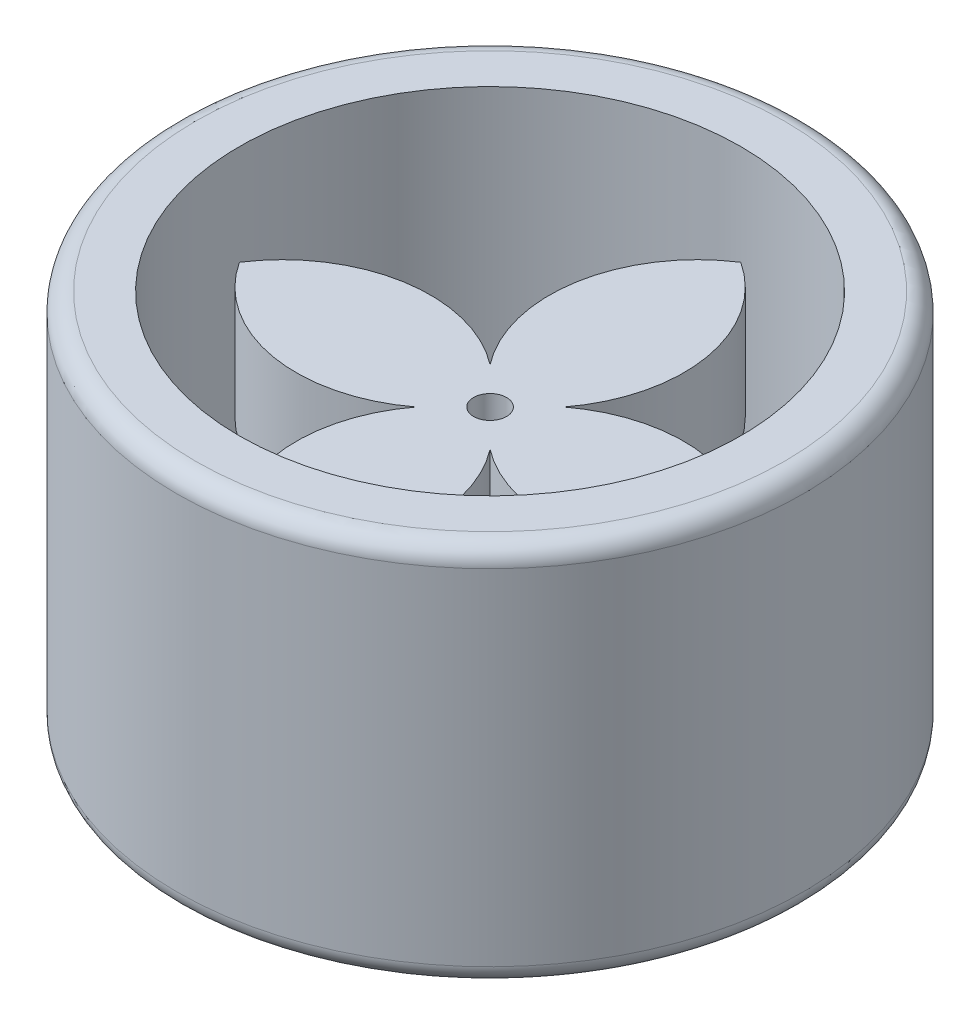
from build123d import *

# Parameters (mm, degrees)
SKETCH1_R           = 50
SKETCH1_R_2         = 40
BOSS_EXTRUDE1_DEPTH = 61
BOSS_EXTRUDE2_START = 27
SKETCH1_3_R         = 2.635
BOSS_EXTRUDE2_DEPTH = 18
FILLET1_R           = 3


with BuildPart() as part:
    # Sketch1 → Boss-Extrude1 (new body)
    with BuildSketch(Plane(origin=(0, 0, 0), x_dir=(1, 0, 0), z_dir=(0, 1, 0))):
        Circle(SKETCH1_R)
        Circle(SKETCH1_R_2, mode=Mode.SUBTRACT)
    extrude(amount=BOSS_EXTRUDE1_DEPTH)

    # Fillet1
    fillet1_edges = [part.edges().sort_by_distance(p)[0] for p in [
        (-50, 61, 0),
        (-50, 0, 0),
    ]]
    fillet(fillet1_edges, radius=FILLET1_R)


with BuildPart() as body_2:
    # Sketch1_3 → Boss-Extrude2 (new body)
    with BuildSketch(Plane(origin=(0, 0, 0), x_dir=(1, 0, 0), z_dir=(0, 1, 0)).offset(BOSS_EXTRUDE2_START)):
        with BuildLine():
            ThreePointArc((5.877030144, 5.877030144), (24.220657484, 10.382837425), (40, 0))
            ThreePointArc((40, 0), (24.220657484, -10.382837425), (5.877030144, -5.877030144))
            ThreePointArc((5.877030144, -5.877030144), (10.382837425, -24.220657484), (0, -40))
            ThreePointArc((0, -40), (-10.382837425, -24.220657484), (-5.877030144, -5.877030144))
            ThreePointArc((-5.877030144, -5.877030144), (-24.220657484, -10.382837425), (-40, 0))
            ThreePointArc((-40, 0), (-24.220657484, 10.382837425), (-5.877030144, 5.877030144))
            ThreePointArc((-5.877030144, 5.877030144), (-10.382837425, 24.220657484), (0, 40))
            ThreePointArc((0, 40), (10.382837425, 24.220657484), (5.877030144, 5.877030144))
        make_face()
        Circle(SKETCH1_3_R, mode=Mode.SUBTRACT)
    extrude(amount=BOSS_EXTRUDE2_DEPTH)


solid = Compound([part.part, body_2.part])
